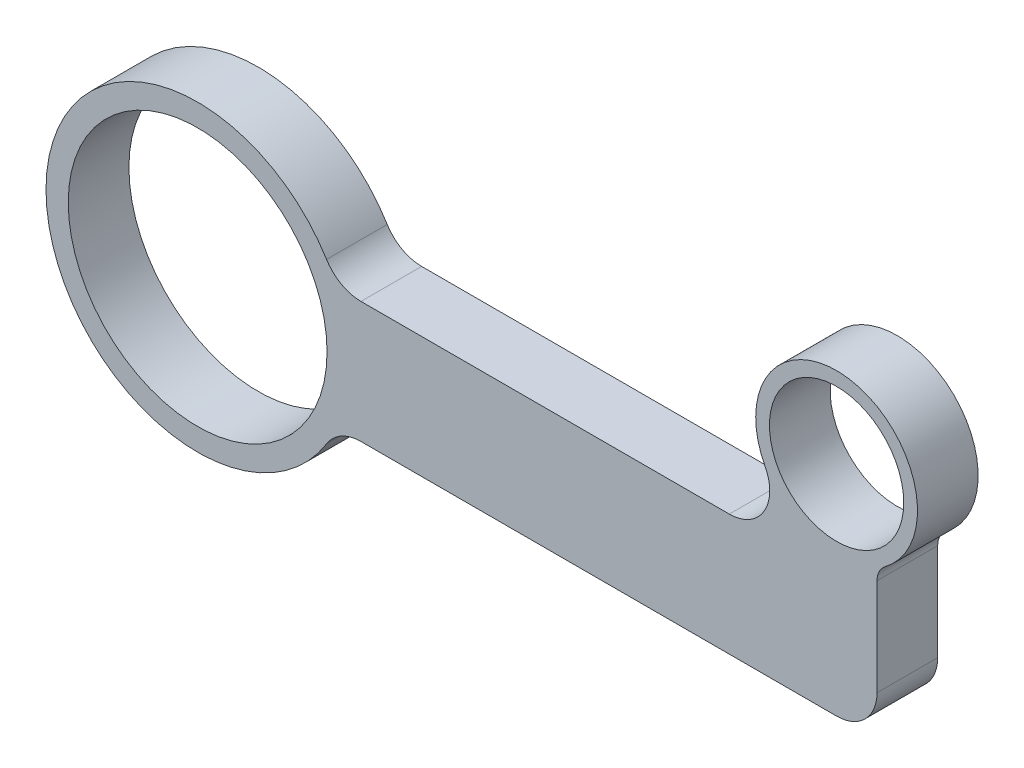
from build123d import *

# Parameters (mm, degrees)
SKETCH1_R           = 40.64
SKETCH1_R_2         = 21.082
BOSS_EXTRUDE1_DEPTH = 19.05


with BuildPart() as part:
    # Sketch1 → Boss-Extrude1 (new body)
    with BuildSketch(Plane.XY):
        with BuildLine():
            Line((-49.036305212, 19.05), (-12.7, 19.05))
            Line((-12.7, 19.05), (66.63309213, 19.05))
            ThreePointArc((66.63309213, 19.05), (77.50872238, 25.1917482), (77.865394753, 37.676666667))
            ThreePointArc((77.865394753, 37.676666667), (86.740959905, 70.989216885), (120.65, 64.77))
            ThreePointArc((120.65, 64.77), (125.73, 49.53), (120.65, 34.29))
            ThreePointArc((120.65, 34.29), (118.290512242, 31.569487758), (115.57, 29.21))
            ThreePointArc((115.57, 29.21), (113.700387337, 26.969806331), (113.03, 24.13))
            Line((113.03, 24.13), (113.03, -6.35))
            ThreePointArc((113.03, -6.35), (109.310256121, -15.330256121), (100.33, -19.05))
            Line((100.33, -19.05), (12.7, -19.05))
            Line((12.7, -19.05), (-49.036305212, -19.05))
            ThreePointArc((-49.036305212, -19.05), (-55.216941357, -20.655418582), (-59.834977799, -25.065789474))
            ThreePointArc((-59.834977799, -25.065789474), (-101.860987289, -47.600385533), (-142.352058824, -22.411764706))
            ThreePointArc((-142.352058824, -22.411764706), (-147.955, 0), (-142.352058824, 22.411764706))
            ThreePointArc((-142.352058824, 22.411764706), (-101.860987289, 47.600385533), (-59.834977799, 25.065789474))
            ThreePointArc((-59.834977799, 25.065789474), (-55.216941357, 20.655418582), (-49.036305212, 19.05))
        make_face()
        with Locations((-100.33, 0)):
            Circle(SKETCH1_R, mode=Mode.SUBTRACT)
        with Locations((100.33, 49.53)):
            Circle(SKETCH1_R_2, mode=Mode.SUBTRACT)
    extrude(amount=BOSS_EXTRUDE1_DEPTH)


solid = part.part
